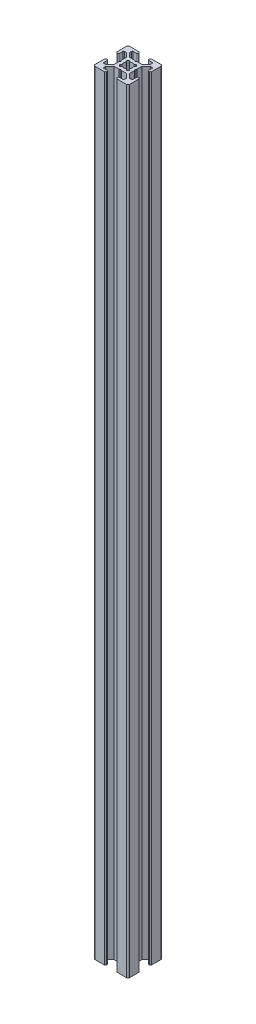
from build123d import *

# Parameters (mm, degrees)
BOSS_EXTRUDE1_DEPTH = 448
FILLET1_R           = 1
CUT_EXTRUDE1_DEPTH  = 449
FILLET2_R           = 0.5
FILLET3_R           = 0.25


with BuildPart() as part:
    # Sketch3 → Boss-Extrude1 (new body)
    with BuildSketch(Plane(origin=(0, 0, 0), x_dir=(1, 0, 0), z_dir=(0, 1, 0))):
        with BuildLine():
            Line((7, 18.5), (7, 19.5))
            ThreePointArc((7, 19.5), (6.646446609, 19.646446609), (6.5, 20))
            Line((6.5, 20), (0, 20))
            Line((0, 20), (0, 13.5))
            ThreePointArc((0, 13.5), (0.353553391, 13.353553391), (0.5, 13))
            Line((0.5, 13), (1.5, 13))
            Line((1.5, 13), (1.5, 16))
            Line((1.5, 16), (3, 16))
            Line((3, 16), (5.5, 13.5))
            Line((5.5, 13.5), (5.5, 10.5))
            Line((5.5, 10.5), (6, 10))
            Line((6, 10), (5.5, 9.5))
            Line((5.5, 9.5), (5.5, 6.5))
            Line((5.5, 6.5), (3, 4))
            Line((3, 4), (1.5, 4))
            Line((1.5, 4), (1.5, 7))
            Line((1.5, 7), (0.5, 7))
            ThreePointArc((0.5, 7), (0.353553391, 6.646446609), (0, 6.5))
            Line((0, 6.5), (0, 0))
            Line((0, 0), (6.5, 0))
            ThreePointArc((6.5, 0), (6.646446609, 0.353553391), (7, 0.5))
            Line((7, 0.5), (7, 1.5))
            Line((7, 1.5), (4, 1.5))
            Line((4, 1.5), (4, 3))
            Line((4, 3), (6.5, 5.5))
            Line((6.5, 5.5), (9.5, 5.5))
            Line((9.5, 5.5), (10, 6))
            Line((10, 6), (10.5, 5.5))
            Line((10.5, 5.5), (13.5, 5.5))
            Line((13.5, 5.5), (16, 3))
            Line((16, 3), (16, 1.5))
            Line((16, 1.5), (13, 1.5))
            Line((13, 1.5), (13, 0.5))
            ThreePointArc((13, 0.5), (13.353553391, 0.353553391), (13.5, 0))
            Line((13.5, 0), (20, 0))
            Line((20, 0), (20, 6.5))
            ThreePointArc((20, 6.5), (19.646446609, 6.646446609), (19.5, 7))
            Line((19.5, 7), (18.5, 7))
            Line((18.5, 7), (18.5, 4))
            Line((18.5, 4), (17, 4))
            Line((17, 4), (14.5, 6.5))
            Line((14.5, 6.5), (14.5, 9.5))
            Line((14.5, 9.5), (14, 10))
            Line((14, 10), (14.5, 10.5))
            Line((14.5, 10.5), (14.5, 13.5))
            Line((14.5, 13.5), (17, 16))
            Line((17, 16), (18.5, 16))
            Line((18.5, 16), (18.5, 13))
            Line((18.5, 13), (19.5, 13))
            ThreePointArc((19.5, 13), (19.646446609, 13.353553391), (20, 13.5))
            Line((20, 13.5), (20, 20))
            Line((20, 20), (13.5, 20))
            ThreePointArc((13.5, 20), (13.353553391, 19.646446609), (13, 19.5))
            Line((13, 19.5), (13, 18.5))
            Line((13, 18.5), (16, 18.5))
            Line((16, 18.5), (16, 17))
            Line((16, 17), (13.5, 14.5))
            Line((13.5, 14.5), (10.5, 14.5))
            Line((10.5, 14.5), (10, 14))
            Line((10, 14), (9.5, 14.5))
            Line((9.5, 14.5), (6.5, 14.5))
            Line((6.5, 14.5), (4, 17))
            Line((4, 17), (4, 18.5))
            Line((4, 18.5), (7, 18.5))
        make_face()
    extrude(amount=BOSS_EXTRUDE1_DEPTH)

    # Fillet1
    fillet1_edges = [part.edges().sort_by_distance(p)[0] for p in [
        (20, 224, 0),
        (0, 224, 0),
        (0, 224, -20),
        (20, 224, -20),
    ]]
    fillet(fillet1_edges, radius=FILLET1_R)

    # Sketch4 → Cut-Extrude1 (cut, through all)
    with BuildSketch(Plane(origin=(0, 448, 0), x_dir=(1, 0, 0), z_dir=(0, 1, 0))):
        with BuildLine():
            Line((10, 11), (11.195582496, 12.195582496))
            ThreePointArc((11.195582496, 12.195582496), (10, 12.5), (8.804417504, 12.195582496))
            Line((8.804417504, 12.195582496), (10, 11))
        make_face()
        with BuildLine():
            ThreePointArc((12.195582496, 11.195582496), (11.767766953, 11.767766953), (11.195582496, 12.195582496))
            Line((11.195582496, 12.195582496), (10, 11))
            Line((10, 11), (11, 10))
            Line((11, 10), (12.195582496, 11.195582496))
        make_face()
        with BuildLine():
            Line((9, 10), (10, 11))
            Line((10, 11), (8.804417504, 12.195582496))
            ThreePointArc((8.804417504, 12.195582496), (8.232233047, 11.767766953), (7.804417504, 11.195582496))
            Line((7.804417504, 11.195582496), (9, 10))
        make_face()
        Polygon((11, 10), (10, 11), (9, 10), (10, 9), align=None)
        with BuildLine():
            Line((7.804417504, 8.804417504), (9, 10))
            Line((9, 10), (7.804417504, 11.195582496))
            ThreePointArc((7.804417504, 11.195582496), (7.5, 10), (7.804417504, 8.804417504))
        make_face()
        with BuildLine():
            Line((10, 9), (9, 10))
            Line((9, 10), (7.804417504, 8.804417504))
            ThreePointArc((7.804417504, 8.804417504), (8.232233047, 8.232233047), (8.804417504, 7.804417504))
            Line((8.804417504, 7.804417504), (10, 9))
        make_face()
        with BuildLine():
            Line((11.195582496, 7.804417504), (10, 9))
            Line((10, 9), (8.804417504, 7.804417504))
            ThreePointArc((8.804417504, 7.804417504), (10, 7.5), (11.195582496, 7.804417504))
        make_face()
        with BuildLine():
            Line((12.195582496, 8.804417504), (11, 10))
            Line((11, 10), (10, 9))
            Line((10, 9), (11.195582496, 7.804417504))
            ThreePointArc((11.195582496, 7.804417504), (11.767766953, 8.232233047), (12.195582496, 8.804417504))
        make_face()
        with BuildLine():
            ThreePointArc((12.5, 10), (12.422700584, 10.616864556), (12.195582496, 11.195582496))
            Line((12.195582496, 11.195582496), (11, 10))
            Line((11, 10), (12.195582496, 8.804417504))
            ThreePointArc((12.195582496, 8.804417504), (12.422700584, 9.383135444), (12.5, 10))
        make_face()
        with BuildLine():
            ThreePointArc((8.804417504, 7.804417504), (8.232233047, 8.232233047), (7.804417504, 8.804417504))
            Line((7.804417504, 8.804417504), (7, 8))
            Line((7, 8), (8, 7))
            Line((8, 7), (8.804417504, 7.804417504))
        make_face()
        with BuildLine():
            Line((13, 8), (12.195582496, 8.804417504))
            ThreePointArc((12.195582496, 8.804417504), (11.767766953, 8.232233047), (11.195582496, 7.804417504))
            Line((11.195582496, 7.804417504), (12, 7))
            Line((12, 7), (13, 8))
        make_face()
        with BuildLine():
            Line((13, 12), (12, 13))
            Line((12, 13), (11.195582496, 12.195582496))
            ThreePointArc((11.195582496, 12.195582496), (11.767766953, 11.767766953), (12.195582496, 11.195582496))
            Line((12.195582496, 11.195582496), (13, 12))
        make_face()
        with BuildLine():
            ThreePointArc((7.804417504, 11.195582496), (8.232233047, 11.767766953), (8.804417504, 12.195582496))
            Line((8.804417504, 12.195582496), (8, 13))
            Line((8, 13), (7, 12))
            Line((7, 12), (7.804417504, 11.195582496))
        make_face()
    extrude(amount=-CUT_EXTRUDE1_DEPTH, mode=Mode.SUBTRACT)

    # Fillet2
    fillet2_edges = [part.edges().sort_by_distance(p)[0] for p in [
        (18.5, 224, -13),
        (18.5, 224, -16),
        (14.5, 224, -10.5),
        (14.5, 224, -9.5),
        (18.5, 224, -4),
        (18.5, 224, -7),
        (13, 224, -1.5),
        (16, 224, -1.5),
        (10.5, 224, -5.5),
        (9.5, 224, -5.5),
        (4, 224, -1.5),
        (7, 224, -1.5),
        (1.5, 224, -7),
        (1.5, 224, -4),
        (5.5, 224, -9.5),
        (5.5, 224, -10.5),
        (1.5, 224, -16),
        (1.5, 224, -13),
        (7, 224, -18.5),
        (4, 224, -18.5),
        (9.5, 224, -14.5),
        (10.5, 224, -14.5),
        (16, 224, -18.5),
        (13, 224, -18.5),
    ]]
    fillet(fillet2_edges, radius=FILLET2_R)

    # Fillet3
    fillet3_edges = [part.edges().sort_by_distance(p)[0] for p in [
        (7, 224, -12),
        (8, 224, -13),
        (12, 224, -13),
        (13, 224, -12),
        (13, 224, -8),
        (12, 224, -7),
        (8, 224, -7),
        (7, 224, -8),
    ]]
    fillet(fillet3_edges, radius=FILLET3_R)


solid = part.part
